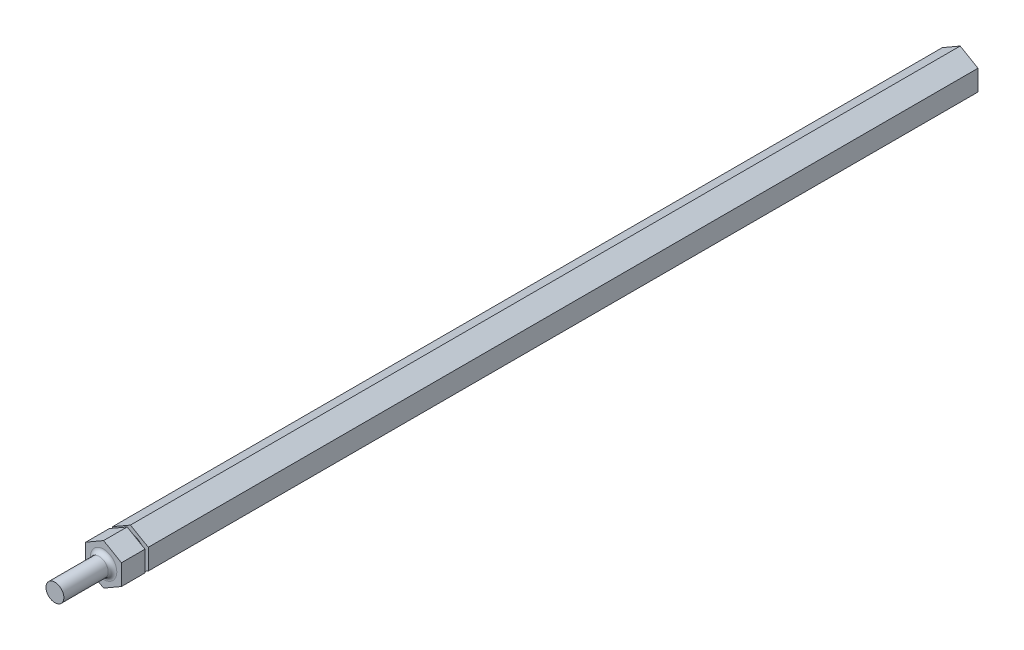
from build123d import *

# Parameters (mm, degrees)
BOSS_EXTRUDE1_DEPTH = 304.8
SKETCH2_R           = 3.175
BOSS_EXTRUDE2_DEPTH = 17.3228
FILLET1_R           = 1.524
SKETCH3_W           = 6.35
SKETCH3_H           = 1.1684


with BuildPart() as part:
    # Sketch1 → Boss-Extrude1 (new body)
    with BuildSketch(Plane.XY):
        Polygon((-6.35, 3.666174209), (-6.35, -3.666174209), (0, -7.332348419), (6.35, -3.666174209), (6.35, 3.666174209), (0, 7.332348419), align=None)
    extrude(amount=BOSS_EXTRUDE1_DEPTH)

    # Sketch2 → Boss-Extrude2 (add)
    with BuildSketch(Plane.XY.offset(304.8)):
        Circle(SKETCH2_R)
    extrude(amount=BOSS_EXTRUDE2_DEPTH)

    # Fillet1
    fillet1_edges = [part.edges().sort_by_distance(p)[0] for p in [
        (-3.175, 0, 304.8),
    ]]
    fillet(fillet1_edges, radius=FILLET1_R)

    # Sketch3 → Cut-Revolve1 (revolve, cut)
    with BuildSketch(Plane(origin=(0, 0, 0), x_dir=(1, 0, 0), z_dir=(0, 1, 0))):
        with Locations((-8.2042, -295.8338)):
            Rectangle(SKETCH3_W, SKETCH3_H)
    revolve(axis=Axis((0, 0, 330.02530499), (0, 0, -1)), mode=Mode.SUBTRACT)


solid = part.part
